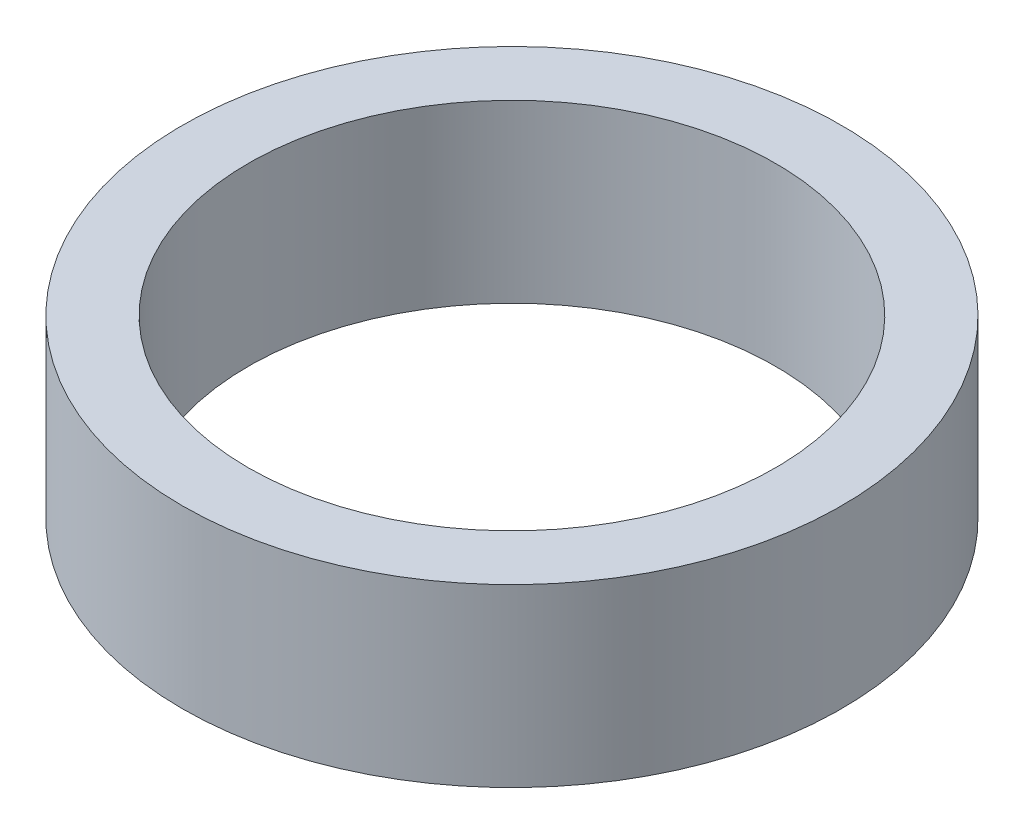
from build123d import *

# Parameters (mm, degrees)
SKETCH1_R           = 22.5
SKETCH1_R_2         = 18
BOSS_EXTRUDE1_DEPTH = 12


with BuildPart() as part:
    # Sketch1 → Boss-Extrude1 (new body)
    with BuildSketch(Plane(origin=(0, 0, 0), x_dir=(1, 0, 0), z_dir=(0, 1, 0))):
        Circle(SKETCH1_R)
        Circle(SKETCH1_R_2, mode=Mode.SUBTRACT)
    extrude(amount=BOSS_EXTRUDE1_DEPTH)


solid = part.part
